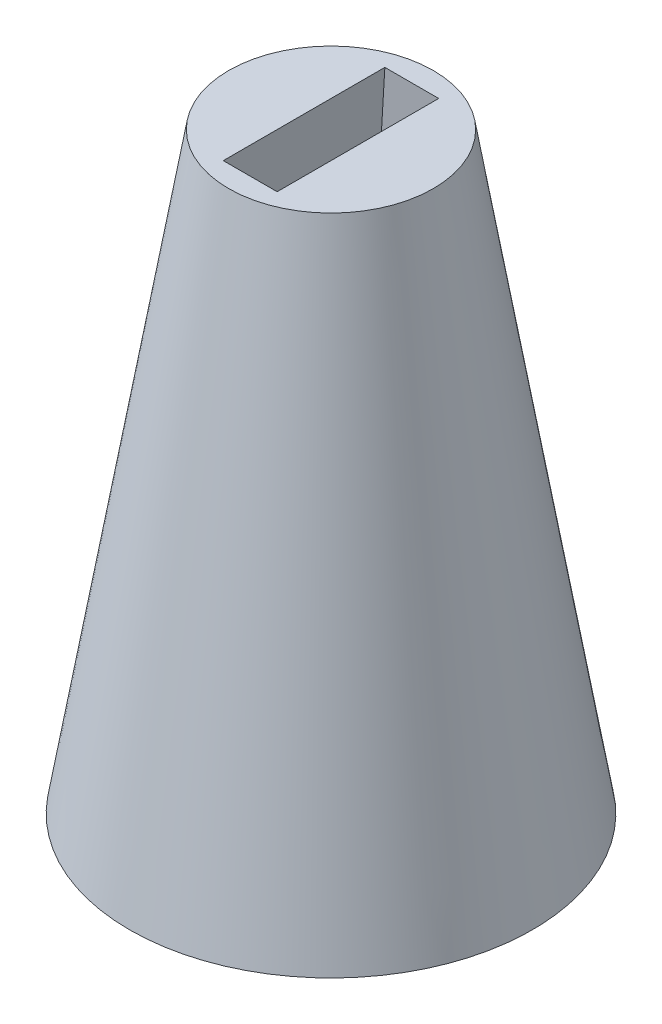
from build123d import *

# Parameters (mm, degrees)
SKETCH_2_R          = 9.5
SKETCH_1_R          = 18.7
SKETCH_5_W          = 11.5
SKETCH_5_H          = 19
CUT_EXTRUDE_1_DEPTH = 32
SKETCH_9_W          = 11.5
SKETCH_9_H          = 19
SKETCH_6_W          = 5
SKETCH_6_H          = 15


with BuildPart() as part:
    # 스케치2 → 로프트1 section 0
    with BuildSketch(Plane(origin=(0, 55, 0), x_dir=(1, 0, 0), z_dir=(0, 1, 0))):
        Circle(SKETCH_2_R)
    # 스케치1 → 로프트1 section 1
    with BuildSketch(Plane(origin=(0, 0, 0), x_dir=(1, 0, 0), z_dir=(0, 1, 0))):
        Circle(SKETCH_1_R)
    loft()

    # 스케치5 → 컷-돌출1 (cut)
    with BuildSketch(Plane.XZ):
        Rectangle(SKETCH_5_W, SKETCH_5_H)
    extrude(amount=-CUT_EXTRUDE_1_DEPTH, mode=Mode.SUBTRACT)

    # 스케치9 → 컷-로프트2 section 0
    with BuildSketch(Plane.XZ.offset(-32)):
        Rectangle(SKETCH_9_W, SKETCH_9_H)
    # 스케치6 → 컷-로프트2 section 1
    with BuildSketch(Plane(origin=(0, 55, 0), x_dir=(1, 0, 0), z_dir=(0, 1, 0))):
        Rectangle(SKETCH_6_W, SKETCH_6_H)
    loft(mode=Mode.SUBTRACT)


solid = part.part
